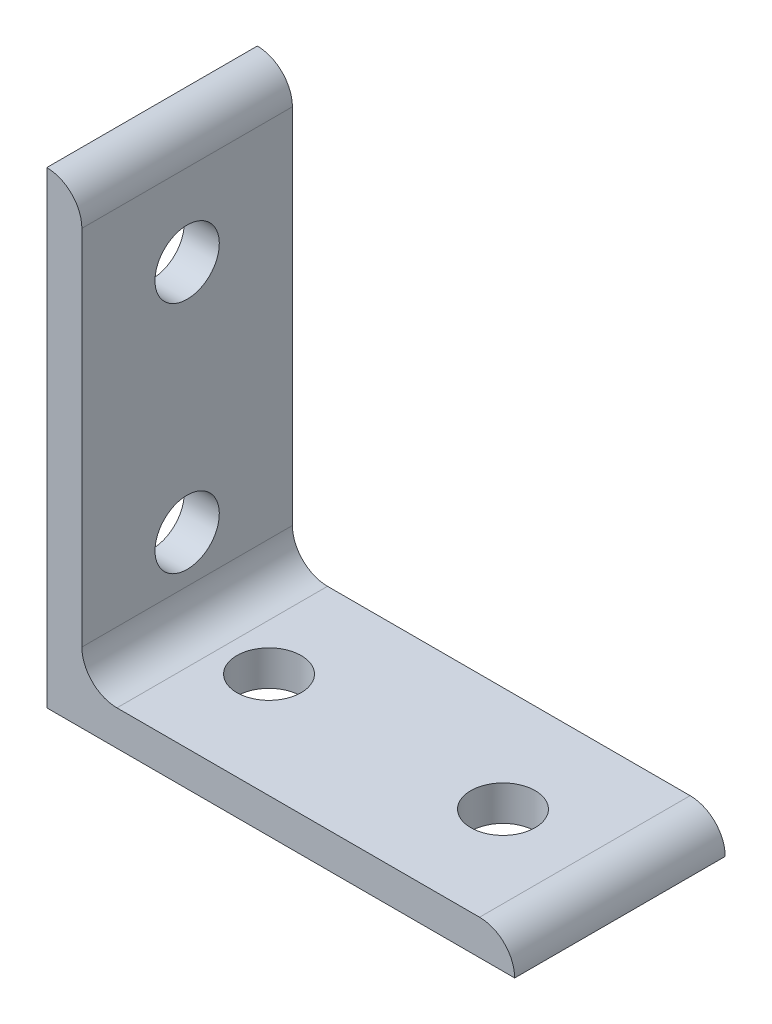
from build123d import *

# Parameters (mm, degrees)
BOSS_EXTRUDE1_DEPTH = 9
SKETCH2_R           = 2.75
CUT_EXTRUDE1_DEPTH  = 41
SKETCH3_R           = 2.75
CUT_EXTRUDE2_DEPTH  = 41


with BuildPart() as part:
    # Sketch1 → Boss-Extrude1 (new body, symmetric)
    with BuildSketch(Plane.XY):
        with BuildLine():
            Line((0, 0), (0, 40))
            ThreePointArc((0, 40), (2.121320344, 39.121320344), (3, 37))
            Line((3, 37), (3, 6))
            ThreePointArc((3, 6), (3.878679656, 3.878679656), (6, 3))
            Line((6, 3), (37, 3))
            ThreePointArc((37, 3), (39.121320344, 2.121320344), (40, 0))
            Line((40, 0), (0, 0))
        make_face()
    extrude(amount=BOSS_EXTRUDE1_DEPTH, both=True)

    # Sketch2 → Cut-Extrude1 (cut, through all)
    with BuildSketch(Plane(origin=(0, 0, 0), x_dir=(1, 0, 0), z_dir=(0, 1, 0))):
        with Locations((10, 0)):
            Circle(SKETCH2_R)
        with Locations((30, 0)):
            Circle(SKETCH2_R)
    extrude(amount=CUT_EXTRUDE1_DEPTH, mode=Mode.SUBTRACT)

    # Sketch3 → Cut-Extrude2 (cut, through all)
    with BuildSketch(Plane(origin=(0, 0, 0), x_dir=(0, 0, -1), z_dir=(1, 0, 0))):
        with Locations((0, 10)):
            Circle(SKETCH3_R)
        with Locations((0, 30)):
            Circle(SKETCH3_R)
    extrude(amount=CUT_EXTRUDE2_DEPTH, mode=Mode.SUBTRACT)


solid = part.part
